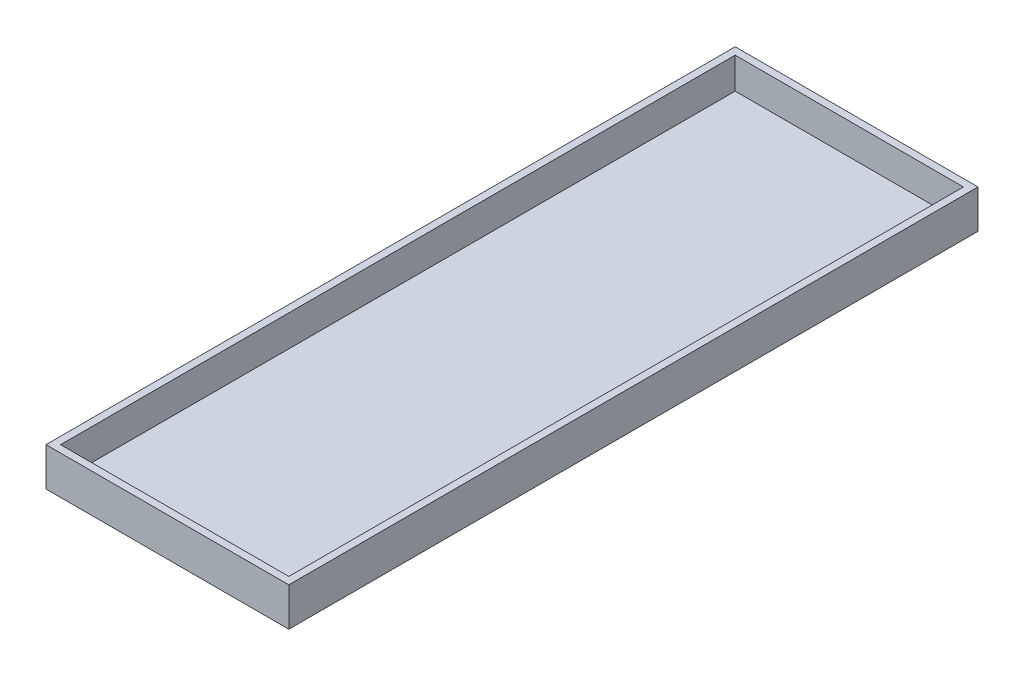
from build123d import *

# Parameters (mm, degrees)
SKETCH1_W           = 60
SKETCH1_H           = 170.3
BOSS_EXTRUDE4_DEPTH = 9.5
SHELL1_T            = -1.8


with BuildPart() as part:
    # Sketch1 → Boss-Extrude4 (new body)
    with BuildSketch(Plane(origin=(0, 0, 0), x_dir=(1, 0, 0), z_dir=(0, 1, 0))):
        with Locations((30, 85.15)):
            Rectangle(SKETCH1_W, SKETCH1_H)
    extrude(amount=BOSS_EXTRUDE4_DEPTH)

    # Shell1
    shell1_openings = [part.faces().sort_by_distance(p)[0] for p in [
        (30, 9.5, -85.15),
    ]]
    offset(amount=SHELL1_T, openings=shell1_openings, kind=Kind.INTERSECTION)


solid = part.part
